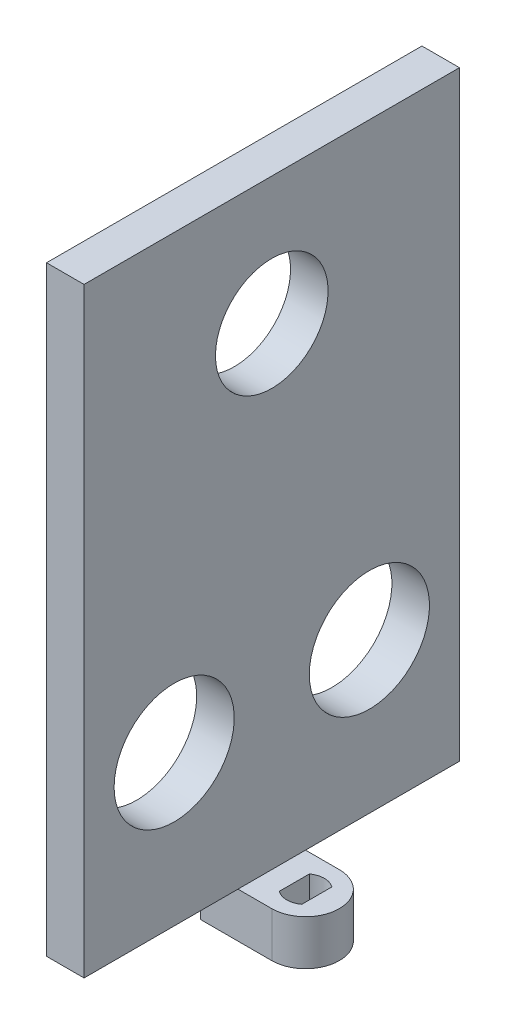
from build123d import *

# Parameters (mm, degrees)
SALIENTE_EXTRUIR1_DEPTH = 6
CROQUIS4_W              = 5
CROQUIS4_H              = 50
SALIENTE_EXTRUIR4_DEPTH = 80
CROQUIS5_R              = 8
CROQUIS5_R_2            = 7.5
CORTAR_EXTRUIR1_DEPTH   = 80


with BuildPart() as part:
    # Croquis1 → Saliente-Extruir1 (new body)
    with BuildSketch(Plane(origin=(0, 0, 0), x_dir=(1, 0, 0), z_dir=(0, 1, 0))):
        with BuildLine():
            Line((-9.5, 4.5), (-9.5, 0))
            Line((-9.5, 0), (-4.5, 0))
            ThreePointArc((-4.5, 0), (-3.181980515, 3.181980515), (0, 4.5))
            Line((0, 4.5), (-9.5, 4.5))
        make_face()
        with BuildLine():
            Line((-4.5, 0), (-9.5, 0))
            Line((-9.5, 0), (-9.5, -4.5))
            Line((-9.5, -4.5), (0, -4.5))
            ThreePointArc((0, -4.5), (-3.181980515, -3.181980515), (-4.5, 0))
        make_face()
        with BuildLine():
            ThreePointArc((0, 4.5), (-3.181980515, 3.181980515), (-4.5, 0))
            Line((-4.5, 0), (-2.5, 0))
            ThreePointArc((-2.5, 0), (-2.236067977, 1.118033989), (-1.5, 2))
            Line((-1.5, 2), (-1.5, 3.446675318))
            Line((-1.5, 3.446675318), (0, 3.446675318))
            Line((0, 3.446675318), (0, 4.5))
        make_face()
        with BuildLine():
            Line((-2.5, 0), (-4.5, 0))
            ThreePointArc((-4.5, 0), (-3.181980515, -3.181980515), (0, -4.5))
            Line((0, -4.5), (0, -3.446675318))
            Line((0, -3.446675318), (-1.5, -3.446675318))
            Line((-1.5, -3.446675318), (-1.5, -2))
            ThreePointArc((-1.5, -2), (-2.236067977, -1.118033989), (-2.5, 0))
        make_face()
        with BuildLine():
            ThreePointArc((-1.5, 2), (-2.236067977, 1.118033989), (-2.5, 0))
            Line((-2.5, 0), (-1.5, 0))
            Line((-1.5, 0), (-1.5, 2))
        make_face()
        with BuildLine():
            Line((-1.5, 0), (-2.5, 0))
            ThreePointArc((-2.5, 0), (-2.236067977, -1.118033989), (-1.5, -2))
            Line((-1.5, -2), (-1.5, 0))
        make_face()
        with BuildLine():
            Line((-1.5, 3.446675318), (-1.5, 2))
            ThreePointArc((-1.5, 2), (-0.790569415, 2.371708245), (0, 2.5))
            Line((0, 2.5), (0, 3.446675318))
            Line((0, 3.446675318), (-1.5, 3.446675318))
        make_face()
        with BuildLine():
            Line((1.5, 3.446675318), (0, 3.446675318))
            Line((0, 3.446675318), (0, 2.5))
            ThreePointArc((0, 2.5), (0.790569415, 2.371708245), (1.5, 2))
            Line((1.5, 2), (1.5, 3.446675318))
        make_face()
        with BuildLine():
            ThreePointArc((0, -2.5), (-0.790569415, -2.371708245), (-1.5, -2))
            Line((-1.5, -2), (-1.5, -3.446675318))
            Line((-1.5, -3.446675318), (0, -3.446675318))
            Line((0, -3.446675318), (0, -2.5))
        make_face()
        with BuildLine():
            Line((0, -2.5), (0, -3.446675318))
            Line((0, -3.446675318), (1.5, -3.446675318))
            Line((1.5, -3.446675318), (1.5, -2))
            ThreePointArc((1.5, -2), (0.790569415, -2.371708245), (0, -2.5))
        make_face()
        with BuildLine():
            ThreePointArc((1.5, -2), (2.236067977, -1.118033989), (2.5, 0))
            Line((2.5, 0), (1.5, 0))
            Line((1.5, 0), (1.5, -2))
        make_face()
        with BuildLine():
            Line((1.5, 0), (2.5, 0))
            ThreePointArc((2.5, 0), (2.236067977, 1.118033989), (1.5, 2))
            Line((1.5, 2), (1.5, 0))
        make_face()
        with BuildLine():
            ThreePointArc((4.5, 0), (3.181980515, 3.181980515), (0, 4.5))
            Line((0, 4.5), (0, 3.446675318))
            Line((0, 3.446675318), (1.5, 3.446675318))
            Line((1.5, 3.446675318), (1.5, 2))
            ThreePointArc((1.5, 2), (2.236067977, 1.118033989), (2.5, 0))
            Line((2.5, 0), (4.5, 0))
        make_face()
        with BuildLine():
            Line((0, -3.446675318), (0, -4.5))
            ThreePointArc((0, -4.5), (3.181980515, -3.181980515), (4.5, 0))
            Line((4.5, 0), (2.5, 0))
            ThreePointArc((2.5, 0), (2.236067977, -1.118033989), (1.5, -2))
            Line((1.5, -2), (1.5, -3.446675318))
            Line((1.5, -3.446675318), (0, -3.446675318))
        make_face()
    extrude(amount=SALIENTE_EXTRUIR1_DEPTH)

    # Croquis4 → Saliente-Extruir4 (add)
    with BuildSketch(Plane(origin=(0, 6, 0), x_dir=(1, 0, 0), z_dir=(0, 1, 0))):
        with Locations((-7, 0)):
            Rectangle(CROQUIS4_W, CROQUIS4_H)
    extrude(amount=SALIENTE_EXTRUIR4_DEPTH)

    # Croquis5 → Cortar-Extruir1 (cut)
    with BuildSketch(Plane.ZY.offset(9.5)):
        with Locations((-13, 26)):
            Circle(CROQUIS5_R)
        with Locations((13, 26)):
            Circle(CROQUIS5_R)
        with Locations((0, 69)):
            Circle(CROQUIS5_R_2)
    extrude(amount=-CORTAR_EXTRUIR1_DEPTH, mode=Mode.SUBTRACT)


solid = part.part
